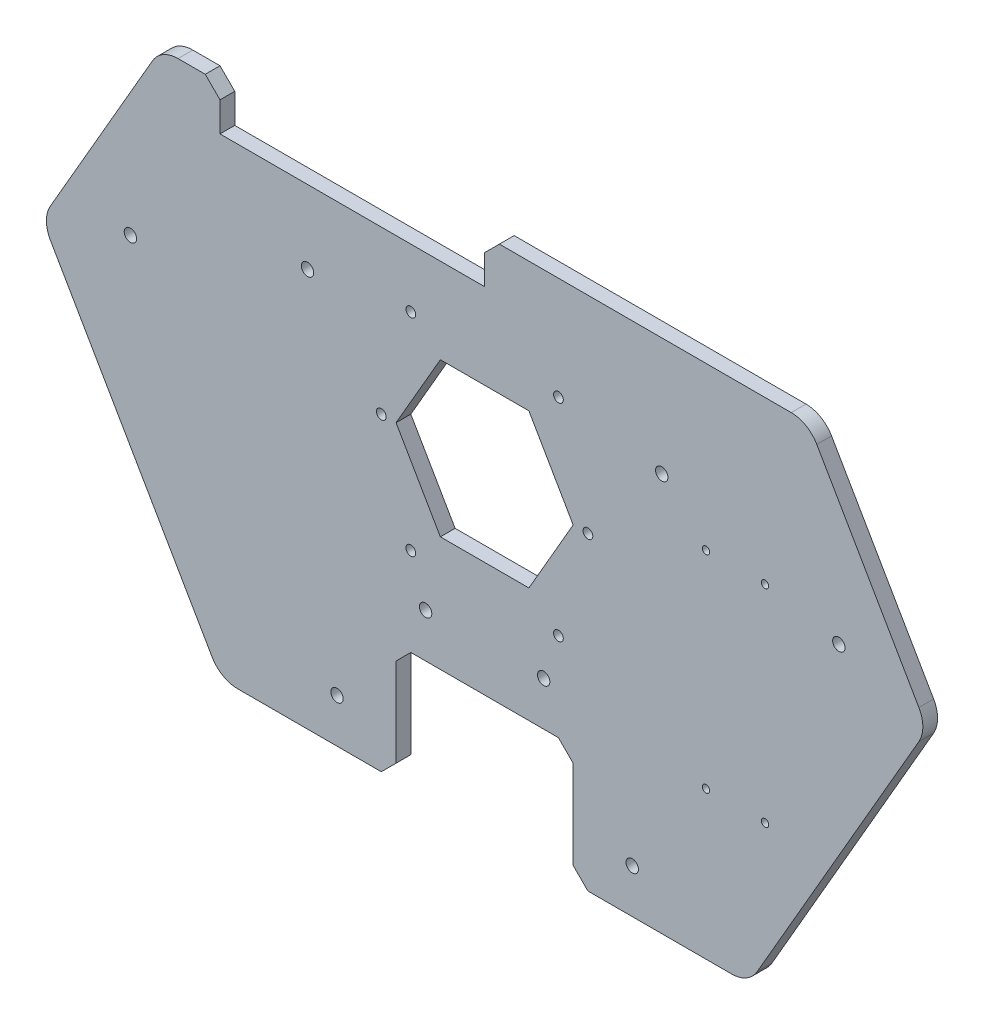
from build123d import *

# Parameters (mm, degrees)
EXTRUDE_1_DEPTH          = 5
CUT_EXTRUDE_2_DEPTH      = 199.494332413
CUT_EXTRUDE_2_DEPTH_BACK = 199.494332413
CUT_EXTRUDE_3_REACH      = 200.494
CHAMFER_1_SIZE           = 5
CUT_EXTRUDE_6_DEPTH      = 199.494332413
CUT_EXTRUDE_6_DEPTH_BACK = 199.494332413
CHAMFER_2_SIZE           = 5
CUT_EXTRUDE_7_REACH      = 185.111
SKETCH_6_R               = 2.1
FILLET_1_R               = 10
M3X0_5_1_D               = 2.5
M3X0_5_1_DEPTH           = 8.5
M3X0_5_1_TIP             = 0.751075774
M4X0_7_2_D               = 3.3
M4X0_7_2_DEPTH           = 11.5
M4X0_7_2_TIP             = 0.991420021


with BuildPart() as part:
    # 草圖1 → 填料-伸長1 (new body)
    with BuildSketch(Plane.XY):
        Polygon((150, 0), (75, 129.903810568), (-75, 129.903810568), (-150, 0), (-75, -129.903810568), (75, -129.903810568), align=None)
    extrude(amount=EXTRUDE_1_DEPTH)

    # 草圖3 → 除料-伸長2 (cut, two sides: drawn at the far end of the back side and taken through both)
    with BuildSketch(Plane.XY.offset(5).offset(-CUT_EXTRUDE_2_DEPTH_BACK)):
        Polygon((-774.886138932, 69.903810568), (-109.641016151, 69.903810568), (-89.641016151, 69.903810568), (-89.641016151, 54.903810568), (0, 54.903810568), (0, 69.903810568), (109.641016151, 69.903810568), (774.886138932, 69.903810568), (774.886138932, 1400.394056128), (-774.886138932, 1400.394056128), align=None)
    extrude(amount=CUT_EXTRUDE_2_DEPTH + CUT_EXTRUDE_2_DEPTH_BACK, mode=Mode.SUBTRACT)

    # 草圖4 → 除料-伸長3 (cut, up to next)
    with BuildSketch(Plane.XY.offset(5), mode=Mode.PRIVATE) as cut_extrude_3_sk1:
        Polygon((30, 0), (15, 25.980762114), (-15, 25.980762114), (-30, 0), (-15, -25.980762114), (15, -25.980762114), align=None)
    cut_extrude_3_tool1 = extrude(cut_extrude_3_sk1.sketch, amount=-CUT_EXTRUDE_3_REACH, mode=Mode.PRIVATE) & part.part
    add(cut_extrude_3_tool1.solids().sort_by_distance((0, 0, 5))[0], mode=Mode.SUBTRACT)

    # 導角1
    chamfer_1_edges = [part.edges().sort_by_distance(p)[0] for p in [
        (0, 69.903810568, 2.5),
        (-89.641016151, 69.903810568, 2.5),
    ]]
    chamfer(chamfer_1_edges, length=CHAMFER_1_SIZE)

    # 草圖5 → 除料-伸長6 (cut, two sides: drawn at the far end of the back side and taken through both)
    with BuildSketch(Plane.XY.offset(5).offset(-CUT_EXTRUDE_6_DEPTH_BACK)):
        Polygon((-692.345987228, -104.903810568), (-89.43375673, -104.903810568), (-30, -104.903810568), (-30, -64.903810568), (30, -64.903810568), (30, -104.903810568), (89.43375673, -104.903810568), (692.345987228, -104.903810568), (692.345987228, -1310.728271565), (-692.345987228, -1310.728271565), align=None)
    extrude(amount=CUT_EXTRUDE_6_DEPTH + CUT_EXTRUDE_6_DEPTH_BACK, mode=Mode.SUBTRACT)

    # 導角2
    chamfer_2_edges = [part.edges().sort_by_distance(p)[0] for p in [
        (30, -104.903810568, 2.5),
        (30, -64.903810568, 2.5),
        (-30, -64.903810568, 2.5),
        (-30, -104.903810568, 2.5),
    ]]
    chamfer(chamfer_2_edges, length=CHAMFER_2_SIZE)

    # 草圖6 → 除料-伸長7 (cut, up to next)
    with BuildSketch(Plane.XY.offset(5), mode=Mode.PRIVATE) as cut_extrude_7_sk1:
        with Locations((-50, -90)):
            Circle(SKETCH_6_R)
    cut_extrude_7_tool1 = extrude(cut_extrude_7_sk1.sketch, amount=-CUT_EXTRUDE_7_REACH, mode=Mode.PRIVATE) & part.part
    # 草圖6 → 除料-伸長7 (cut, up to next)
    with BuildSketch(Plane.XY.offset(5), mode=Mode.PRIVATE) as cut_extrude_7_sk2:
        with Locations((-120, 10)):
            Circle(SKETCH_6_R)
    cut_extrude_7_tool2 = extrude(cut_extrude_7_sk2.sketch, amount=-CUT_EXTRUDE_7_REACH, mode=Mode.PRIVATE) & part.part
    # 草圖6 → 除料-伸長7 (cut, up to next)
    with BuildSketch(Plane.XY.offset(5), mode=Mode.PRIVATE) as cut_extrude_7_sk3:
        with Locations((-60, 30)):
            Circle(SKETCH_6_R)
    cut_extrude_7_tool3 = extrude(cut_extrude_7_sk3.sketch, amount=-CUT_EXTRUDE_7_REACH, mode=Mode.PRIVATE) & part.part
    # 草圖6 → 除料-伸長7 (cut, up to next)
    with BuildSketch(Plane.XY.offset(5), mode=Mode.PRIVATE) as cut_extrude_7_sk4:
        with Locations((-20, -50)):
            Circle(SKETCH_6_R)
    cut_extrude_7_tool4 = extrude(cut_extrude_7_sk4.sketch, amount=-CUT_EXTRUDE_7_REACH, mode=Mode.PRIVATE) & part.part
    cut_extrude_7_1 = cut_extrude_7_tool1.solids().sort_by_distance((-50, -90, 5))[0]
    add(cut_extrude_7_1, mode=Mode.SUBTRACT)
    cut_extrude_7_2 = cut_extrude_7_tool2.solids().sort_by_distance((-120, 10, 5))[0]
    add(cut_extrude_7_2, mode=Mode.SUBTRACT)
    cut_extrude_7_3 = cut_extrude_7_tool3.solids().sort_by_distance((-60, 30, 5))[0]
    add(cut_extrude_7_3, mode=Mode.SUBTRACT)
    cut_extrude_7_4 = cut_extrude_7_tool4.solids().sort_by_distance((-20, -50, 5))[0]
    add(cut_extrude_7_4, mode=Mode.SUBTRACT)
    cut_extrude_7 = cut_extrude_7_1 + cut_extrude_7_2 + cut_extrude_7_3 + cut_extrude_7_4  # 除料-伸長7 as one shape, for the pattern or mirror that repeats it

    # 鏡射1: 除料-伸長7 across plane
    add(cut_extrude_7.mirror(Plane(origin=(0, 0, 0), x_dir=(0, 0, 1), z_dir=(1, 0, 0))), mode=Mode.SUBTRACT)

    # 圓角1
    fillet_1_edges = [part.edges().sort_by_distance(p)[0] for p in [
        (109.641016151, 69.903810568, 2.5),
        (150, 0, 2.5),
        (89.43375673, -104.903810568, 2.5),
        (-89.43375673, -104.903810568, 2.5),
        (-150, 0, 2.5),
        (-109.641016151, 69.903810568, 2.5),
    ]]
    fillet(fillet_1_edges, radius=FILLET_1_R)

    # M3x0.5 螺紋孔1
    with Locations(Plane.XY.offset(5)):
        with Locations((95, 15.096189432), (75, -54.903810568), (75, 15.096189432), (95, -54.903810568)):
            Hole(M3X0_5_1_D / 2, depth=M3X0_5_1_DEPTH)
            with Locations((0, 0, -(M3X0_5_1_DEPTH + M3X0_5_1_TIP / 2))):  # 118° drill point
                Cone(0, M3X0_5_1_D / 2, M3X0_5_1_TIP, mode=Mode.SUBTRACT)

    # M4x0.7 螺紋孔2
    with Locations(Plane.XY.offset(5)):
        with Locations((25, 35), (-25, -35), (-25, 35), (25, -35), (-35, 0), (35, 0)):
            Hole(M4X0_7_2_D / 2, depth=M4X0_7_2_DEPTH)
            with Locations((0, 0, -(M4X0_7_2_DEPTH + M4X0_7_2_TIP / 2))):  # 118° drill point
                Cone(0, M4X0_7_2_D / 2, M4X0_7_2_TIP, mode=Mode.SUBTRACT)


solid = part.part
